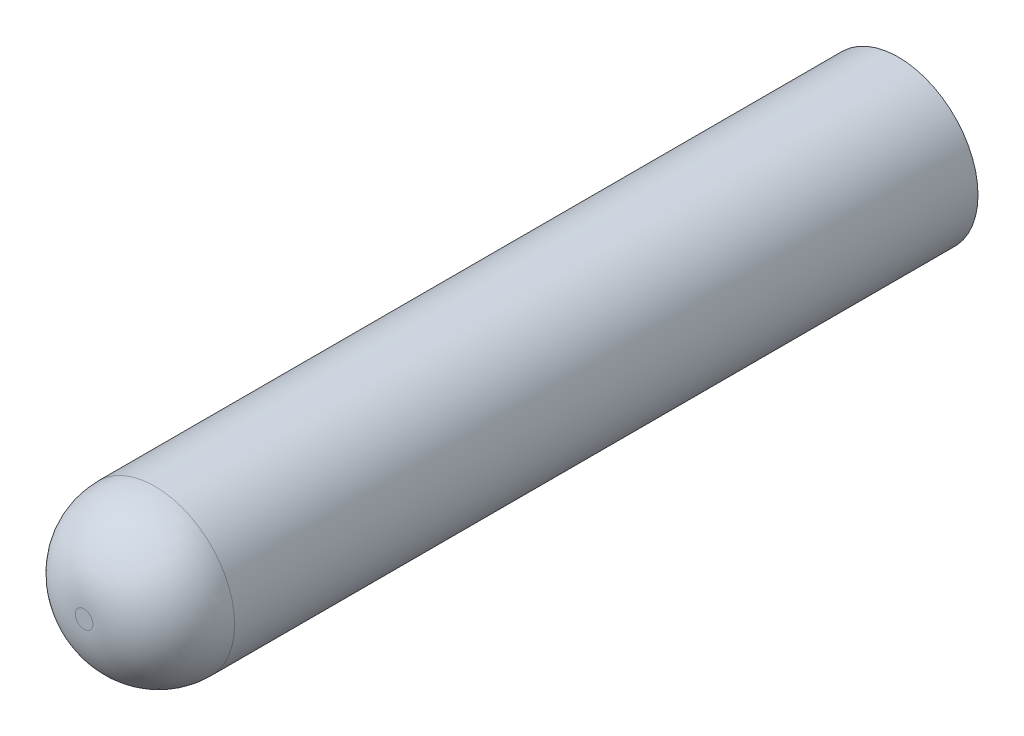
from build123d import *

# Parameters (mm, degrees)
SKETCH_1_R          = 2.25
EXTRUDE_2_DEPTH     = 23
SKETCH_7_W          = 2.4
SKETCH_7_H          = 2.4
CUT_EXTRUDE_3_DEPTH = 4.5
FILLET_2_R          = 2


with BuildPart() as part:
    # 草图1 → 凸台-拉伸2 (new body)
    with BuildSketch(Plane.XY):
        Circle(SKETCH_1_R)
    extrude(amount=EXTRUDE_2_DEPTH)

    # 草图7 → 切除-拉伸3 (cut)
    with BuildSketch(Plane.XY):
        Rectangle(SKETCH_7_W, SKETCH_7_H)
    extrude(amount=CUT_EXTRUDE_3_DEPTH, mode=Mode.SUBTRACT)

    # 圆角2
    fillet_2_edges = [part.edges().sort_by_distance(p)[0] for p in [
        (-2.25, 0, 23),
    ]]
    fillet(fillet_2_edges, radius=FILLET_2_R)


solid = part.part
